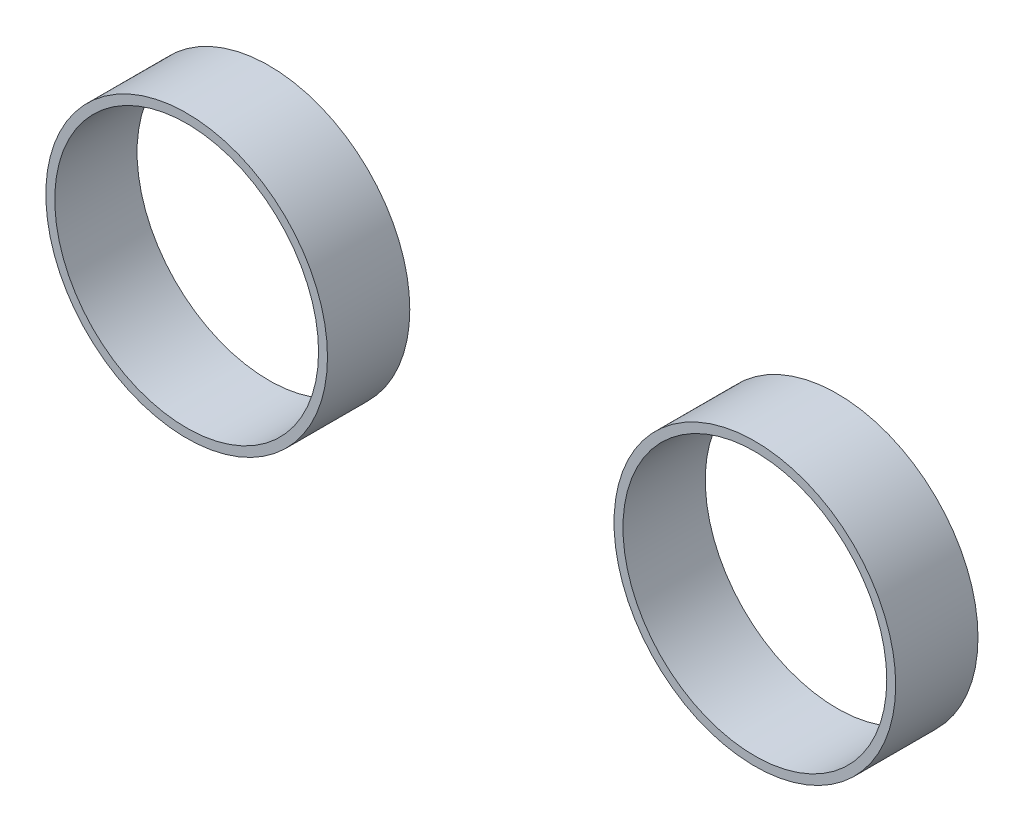
from build123d import *

# Parameters (mm, degrees)
SKETCH1_R             = 69.4
SKETCH1_R_2           = 65
BOSS_EXTRUDE1_DEPTH   = 40.56
BOSS_EXTRUDE1_2_DEPTH = 40.56


with BuildPart() as part:
    # Sketch1 → Boss-Extrude1 (new body)
    with BuildSketch(Plane.XY):
        with Locations((1435.980472759, -423.382336202)):
            Circle(SKETCH1_R)
        with Locations((1435.980472759, -423.382336202)):
            Circle(SKETCH1_R_2, mode=Mode.SUBTRACT)
    extrude(amount=BOSS_EXTRUDE1_DEPTH)


with BuildPart() as body_2:
    # Sketch1 → Boss-Extrude1 2 (new body)
    with BuildSketch(Plane.XY):
        with Locations((1715.980472759, -423.382336201)):
            Circle(SKETCH1_R)
        with Locations((1715.980472759, -423.382336201)):
            Circle(SKETCH1_R_2, mode=Mode.SUBTRACT)
    extrude(amount=BOSS_EXTRUDE1_2_DEPTH)


solid = Compound([part.part, body_2.part])
